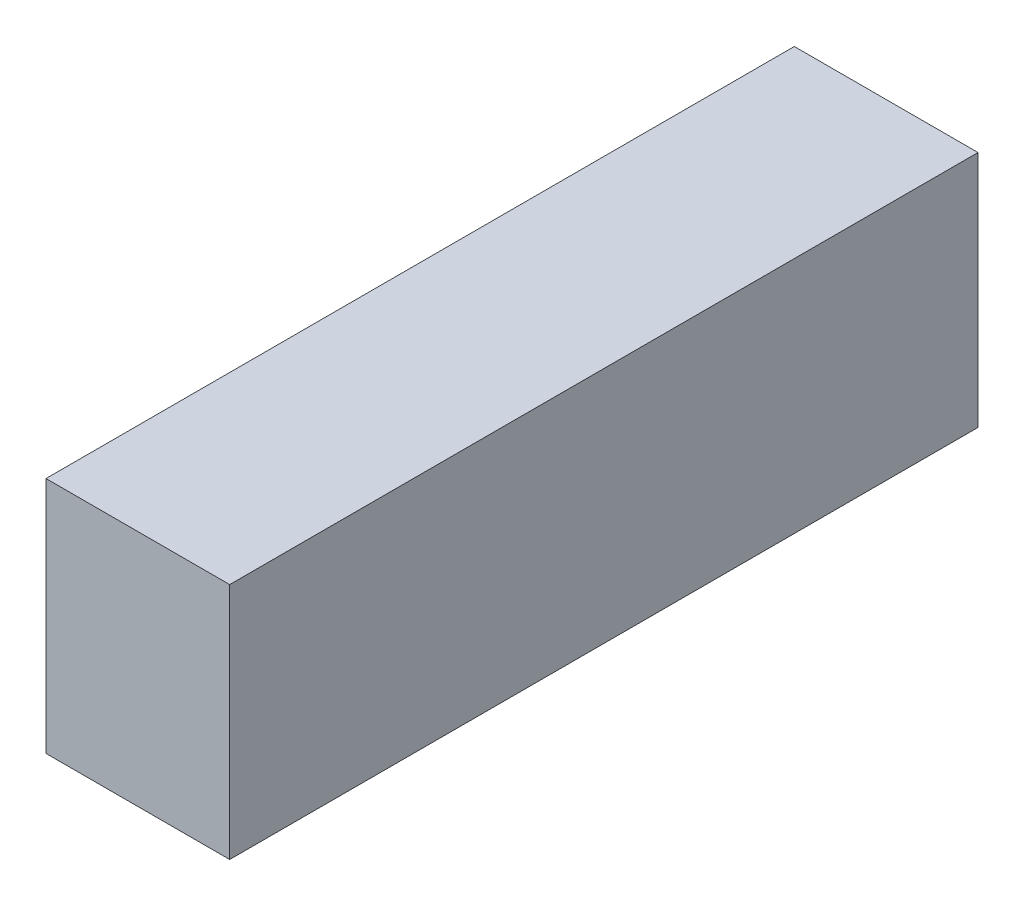
from build123d import *

# Parameters (mm, degrees)
SKETCH1_W           = 17.145
SKETCH1_H           = 69.85
BOSS_EXTRUDE1_DEPTH = 11.1125


with BuildPart() as part:
    # Sketch1 → Boss-Extrude1 (new body, symmetric)
    with BuildSketch(Plane(origin=(0, 0, 0), x_dir=(1, 0, 0), z_dir=(0, 1, 0))):
        Rectangle(SKETCH1_W, SKETCH1_H)
    extrude(amount=BOSS_EXTRUDE1_DEPTH, both=True)


solid = part.part
